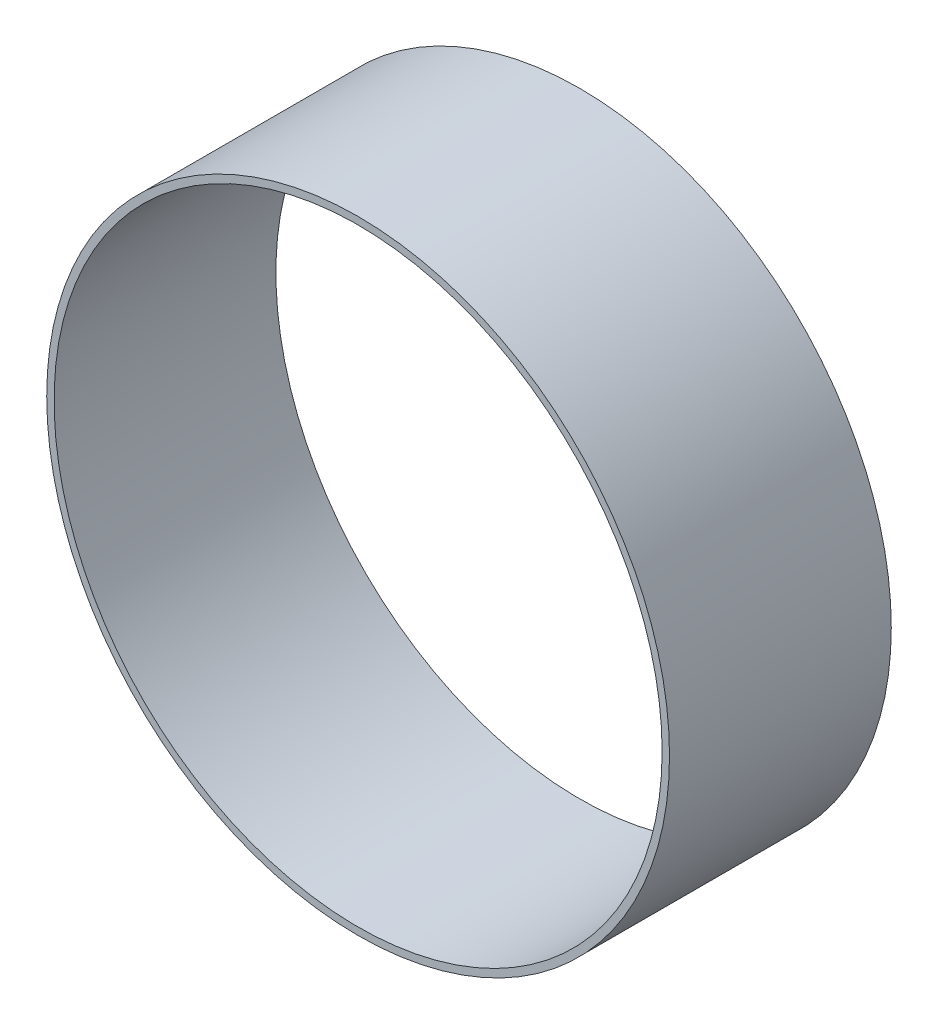
from build123d import *

# Parameters (mm, degrees)
CROQUIS1_R              = 8.425
CROQUIS1_R_2            = 8.225
SALIENTE_EXTRUIR1_DEPTH = 6


with BuildPart() as part:
    # Croquis1 → Saliente-Extruir1 (new body)
    with BuildSketch(Plane.XY):
        Circle(CROQUIS1_R)
        Circle(CROQUIS1_R_2, mode=Mode.SUBTRACT)
    extrude(amount=SALIENTE_EXTRUIR1_DEPTH)


solid = part.part
